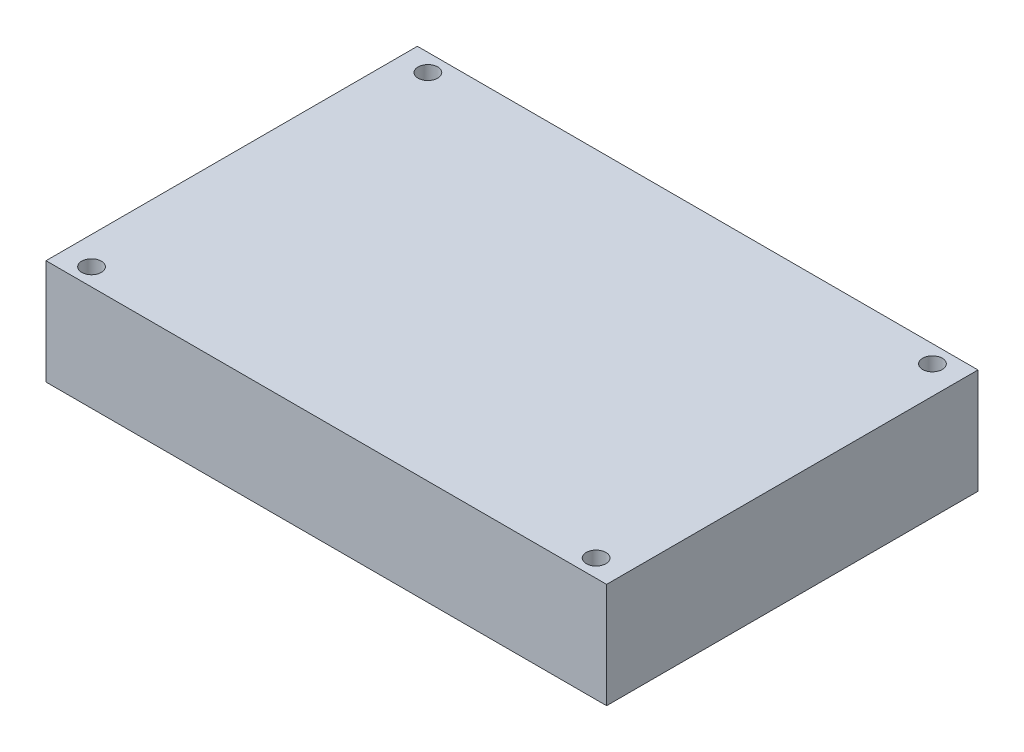
from build123d import *

# Parameters (mm, degrees)
SKETCH_1_R      = 1.4
EXTRUDE_1_DEPTH = 15


with BuildPart() as part:
    # 草图1 → 凸台-拉伸1 (new body)
    with BuildSketch(Plane(origin=(0, 0, 0), x_dir=(1, 0, 0), z_dir=(0, 1, 0))):
        Polygon((80, 53), (80, 0), (0, 0), (0, 53), (39.5, 53), (41.5, 53), align=None)
        with Locations((76, 50.5)):
            Circle(SKETCH_1_R, mode=Mode.SUBTRACT)
        with Locations((76, 2.5)):
            Circle(SKETCH_1_R, mode=Mode.SUBTRACT)
        with Locations((4, 50.5)):
            Circle(SKETCH_1_R, mode=Mode.SUBTRACT)
        with Locations((4, 2.5)):
            Circle(SKETCH_1_R, mode=Mode.SUBTRACT)
    extrude(amount=EXTRUDE_1_DEPTH)


solid = part.part
